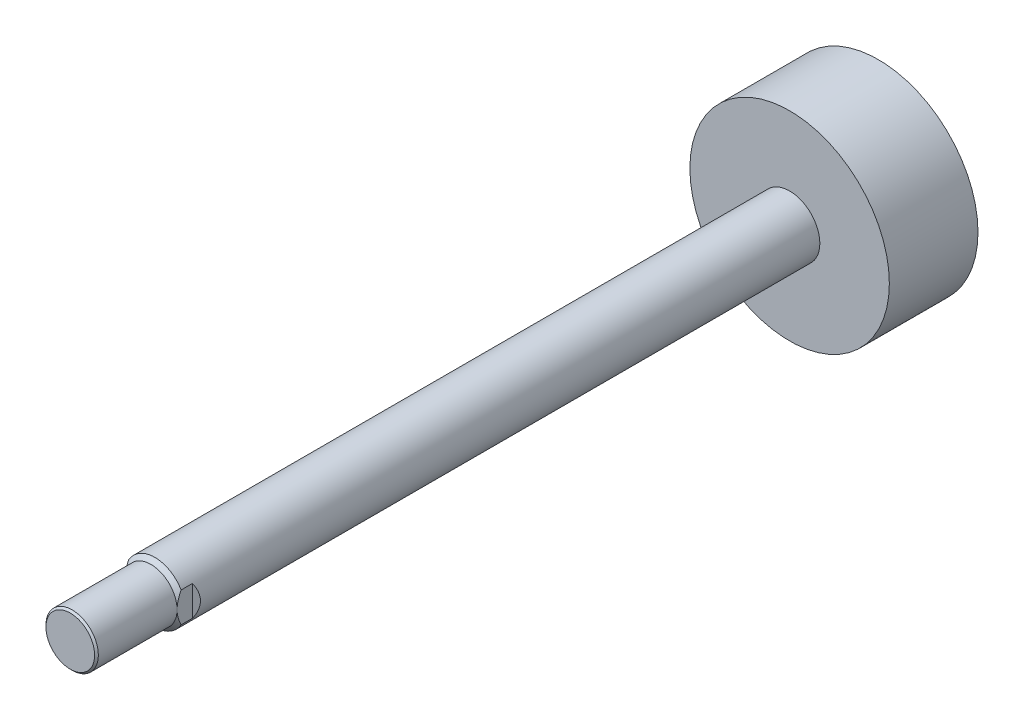
from build123d import *

# Parameters (mm, degrees)
CUT_EXTRUDE_1_DEPTH      = 15
CUT_EXTRUDE_1_DEPTH_BACK = 15
CUT_EXTRUDE_2_DEPTH      = 15
CUT_EXTRUDE_2_DEPTH_BACK = 15


with BuildPart() as part:
    # 草图1 → 旋转1 (revolve)
    with BuildSketch(Plane(origin=(0, 0, 0), x_dir=(0, 0, -1), z_dir=(1, 0, 0))):
        Polygon((-52, 0), (-52, 12.08), (-51.08, 13), (-12, 13), (-10, 15), (305, 15), (305, 49.5), (349, 49.5), (349, 0), align=None)
    revolve(axis=Axis((0, 0, -349), (0, 0, 1)))

    # 草图2 → 切除-拉伸1 (cut, two sides: drawn at the far end of the back side and taken through both)
    with BuildSketch(Plane(origin=(0, 0, 0), x_dir=(1, 0, 0), z_dir=(0, 1, 0)).offset(-CUT_EXTRUDE_1_DEPTH_BACK)):
        Polygon((13, -4.4), (13, -12), (15, -12), (15, -2.4), align=None)
    extrude(amount=CUT_EXTRUDE_1_DEPTH + CUT_EXTRUDE_1_DEPTH_BACK, mode=Mode.SUBTRACT)

    # 草图3 → 切除-拉伸2 (cut, two sides: drawn at the far end of the back side and taken through both)
    with BuildSketch(Plane(origin=(0, 0, 0), x_dir=(1, 0, 0), z_dir=(0, 1, 0)).offset(-CUT_EXTRUDE_2_DEPTH_BACK)):
        Polygon((-15, -2.4), (-15, -12), (-13, -12), (-13, -4.4), align=None)
    extrude(amount=CUT_EXTRUDE_2_DEPTH + CUT_EXTRUDE_2_DEPTH_BACK, mode=Mode.SUBTRACT)


solid = part.part
